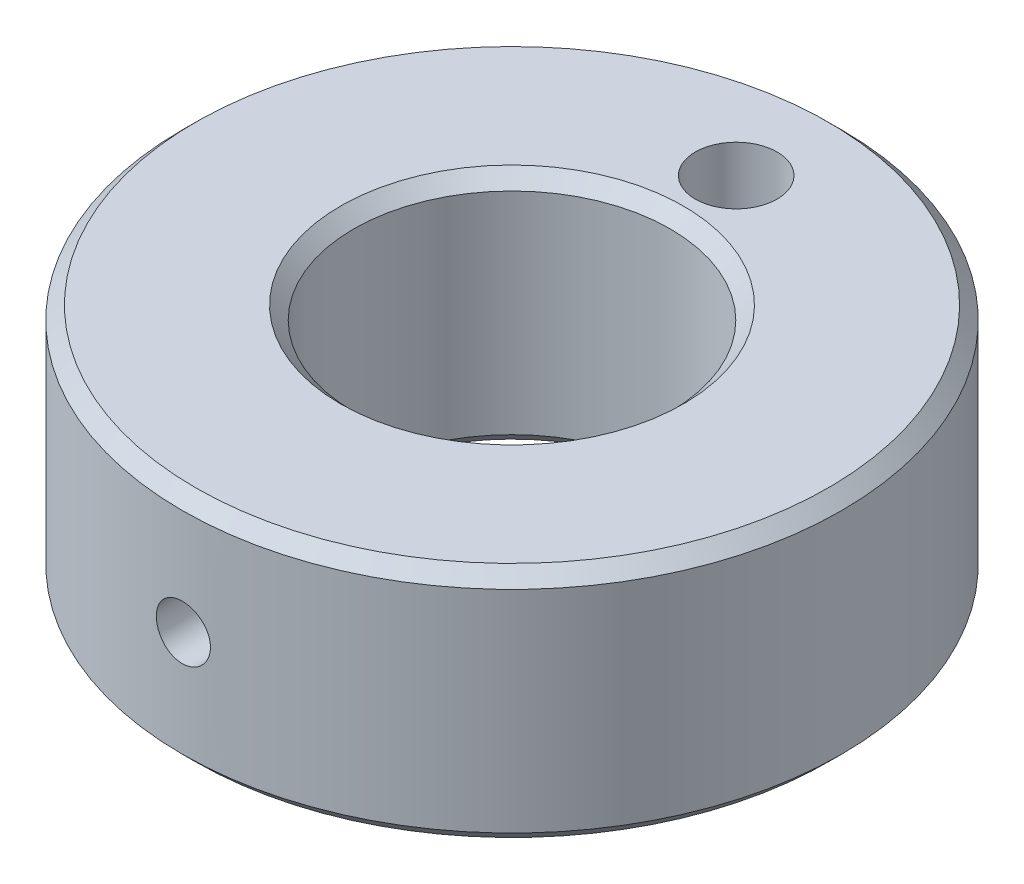
from build123d import *

# Parameters (mm, degrees)
SKETCH1_R                      = 12.5
SKETCH1_R_2                    = 6
BOSS_EXTRUDE1_DEPTH            = 9
CHAMFER1_SIZE                  = 0.5
M2_5X0_45_TAPPED_HOLE1_REACH   = 31.364
M2_5X0_45_TAPPED_HOLE1_BORE_R  = 1.025
F_3_1_3_1_DIAMETER_HOLE1_D     = 3.1
F_3_1_3_1_DIAMETER_HOLE1_DEPTH = 3
F_3_1_3_1_DIAMETER_HOLE1_TIP   = 0.931333959


with BuildPart() as part:
    # Sketch1 → Boss-Extrude1 (new body)
    with BuildSketch(Plane(origin=(0, 0, 0), x_dir=(1, 0, 0), z_dir=(0, 1, 0))):
        with Locations(Location((0, 0, 0), (0, 0, 270))):
            Circle(SKETCH1_R)
        with Locations(Location((0, 0, 0), (0, 0, 270))):
            Circle(SKETCH1_R_2, mode=Mode.SUBTRACT)
    extrude(amount=BOSS_EXTRUDE1_DEPTH)

    # Chamfer1
    chamfer1_edges = [part.edges().sort_by_distance(p)[0] for p in [
        (0, 0, -12.5),
        (0, 9, -12.5),
        (0, 0, -6),
        (0, 9, -6),
    ]]
    chamfer(chamfer1_edges, length=CHAMFER1_SIZE)

    # M2.5x0.45 Tapped Hole1 bore → M2.5x0.45 Tapped Hole1 (cut, up to next)
    with BuildSketch(Plane.XY.offset(12.5), mode=Mode.PRIVATE) as m2_5x0_45_tapped_hole1_sk1:
        with Locations((0, 4.5)):
            Circle(M2_5X0_45_TAPPED_HOLE1_BORE_R)
    m2_5x0_45_tapped_hole1_tool1 = extrude(m2_5x0_45_tapped_hole1_sk1.sketch, amount=-M2_5X0_45_TAPPED_HOLE1_REACH, mode=Mode.PRIVATE) & part.part
    add(m2_5x0_45_tapped_hole1_tool1.solids().sort_by_distance((0, 4.5, 12.5))[0], mode=Mode.SUBTRACT)

    # Ø3.1 (3.1) Diameter Hole1
    with Locations(Plane(origin=(0, 9, 0), x_dir=(1, 0, 0), z_dir=(0, 1, 0))):
        with Locations((0, 8.5)):
            Hole(F_3_1_3_1_DIAMETER_HOLE1_D / 2, depth=F_3_1_3_1_DIAMETER_HOLE1_DEPTH)
            with Locations((0, 0, -(F_3_1_3_1_DIAMETER_HOLE1_DEPTH + F_3_1_3_1_DIAMETER_HOLE1_TIP / 2))):  # 118° drill point
                Cone(0, F_3_1_3_1_DIAMETER_HOLE1_D / 2, F_3_1_3_1_DIAMETER_HOLE1_TIP, mode=Mode.SUBTRACT)


solid = part.part
